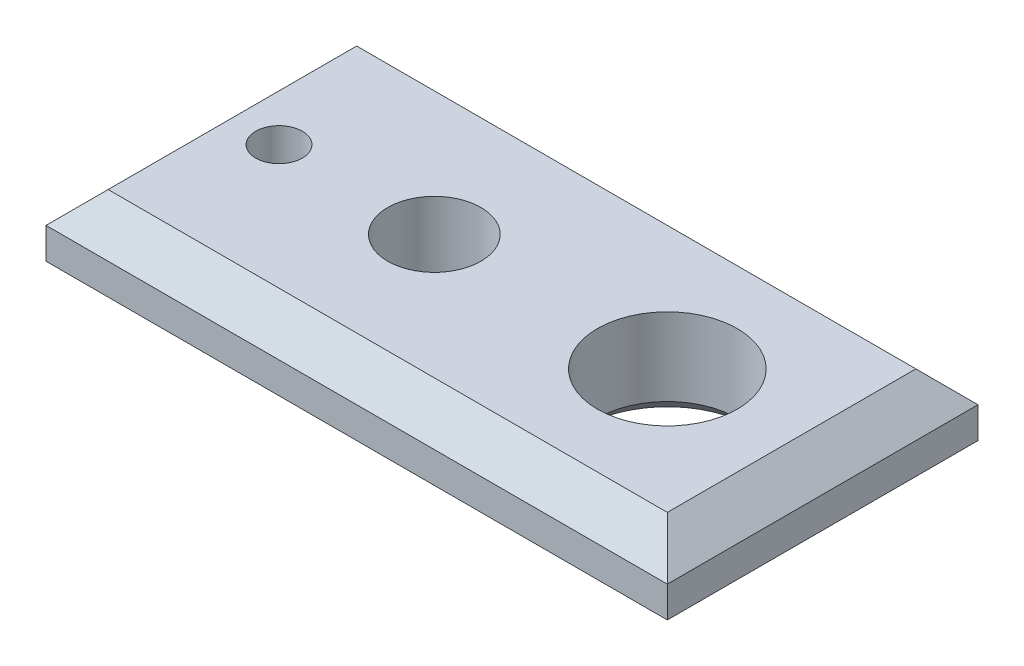
from build123d import *

# Parameters (mm, degrees)
CROQUIS1_W              = 200
CROQUIS1_H              = 100
SALIENTE_EXTRUIR1_DEPTH = 10
CROQUIS2_W              = 180
CROQUIS2_H              = 80
CROQUIS3_W              = 180
CROQUIS3_H              = 80
CROQUIS4_R              = 7.5
CROQUIS4_R_2            = 15
CROQUIS4_R_3            = 22.5
CORTAR_EXTRUIR1_DEPTH   = 30
CHAFL_N2_SIZE           = 5


with BuildPart() as part:
    # Croquis1 → Saliente-Extruir1 (new body)
    with BuildSketch(Plane(origin=(0, 0, 0), x_dir=(1, 0, 0), z_dir=(0, 1, 0))):
        Rectangle(CROQUIS1_W, CROQUIS1_H)
    extrude(amount=SALIENTE_EXTRUIR1_DEPTH)

    # Croquis2 → section 0 of recubrir1
    with BuildSketch(Plane(origin=(0, -10, 0), x_dir=(1, 0, 0), z_dir=(0, 1, 0)), mode=Mode.PRIVATE) as recubrir1_s0:
        Rectangle(CROQUIS2_W, CROQUIS2_H)
    # loft up to a face of the part (recubrir1)
    loft([recubrir1_s0.sketch, part.faces().sort_by_distance((0, 0, 0))[0]])

    # Croquis3 → section 0 of recubrir2
    with BuildSketch(Plane(origin=(0, 20, 0), x_dir=(1, 0, 0), z_dir=(0, 1, 0)), mode=Mode.PRIVATE) as recubrir2_s0:
        Rectangle(CROQUIS3_W, CROQUIS3_H)
    # loft up to a face of the part (recubrir2)
    loft([recubrir2_s0.sketch, part.faces().sort_by_distance((0, 10, 0))[0]])

    # Croquis4 → Cortar-Extruir1 (cut)
    with BuildSketch(Plane(origin=(0, 20, 0), x_dir=(1, 0, 0), z_dir=(0, 1, 0))):
        with Locations((-75, 0)):
            Circle(CROQUIS4_R)
        with Locations((-25, 0)):
            Circle(CROQUIS4_R_2)
        with Locations((50, 0)):
            Circle(CROQUIS4_R_3)
    extrude(amount=-CORTAR_EXTRUIR1_DEPTH, mode=Mode.SUBTRACT)

    # Chaflán2
    chafl_n2_edges = [part.edges().sort_by_distance(p)[0] for p in [
        (-82.5, -10, 0),
        (-40, -10, 0),
        (27.5, -10, 0),
    ]]
    chamfer(chafl_n2_edges, length=CHAFL_N2_SIZE)


solid = part.part
